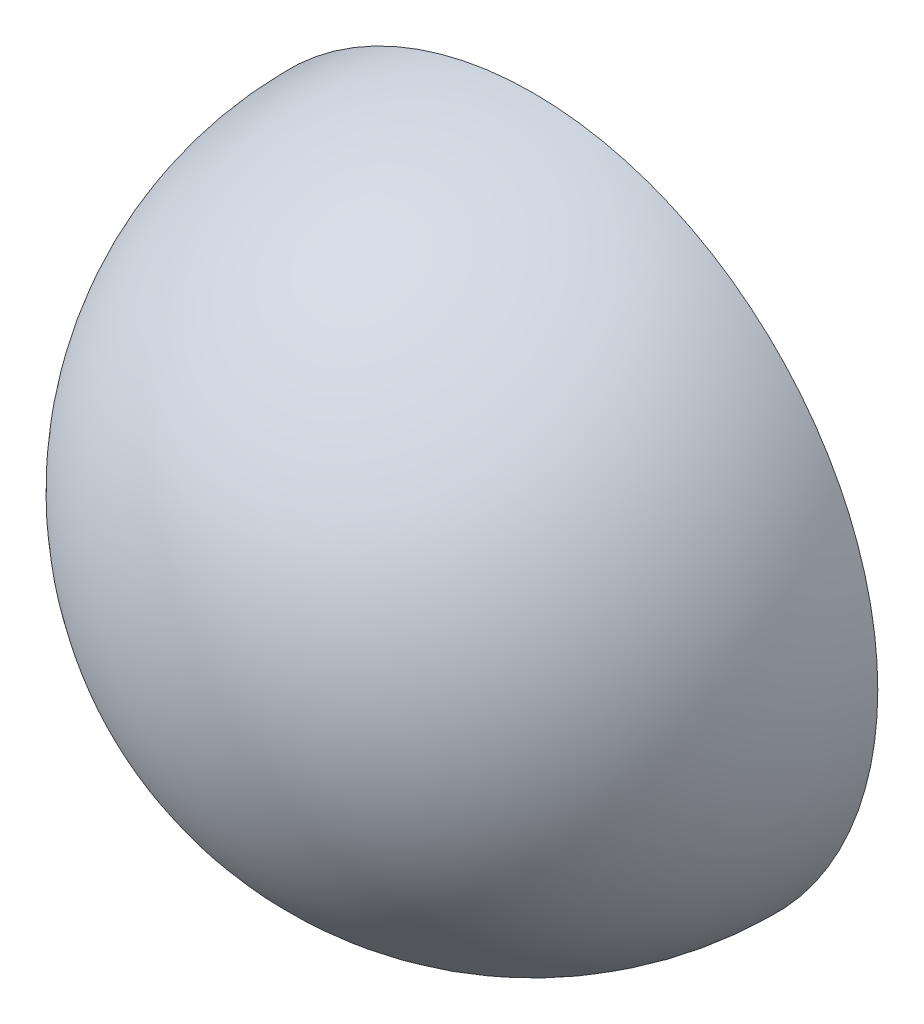
from build123d import *


with BuildPart() as part:
    # Sketch1 → Revolve1 (revolve)
    with BuildSketch(Plane(origin=(0, 0, 0), x_dir=(1, 0, 0), z_dir=(0, 1, 0))):
        with BuildLine():
            Line((-1.25, 0), (0, 0))
            Line((0, 0), (0, -1.25))
            ThreePointArc((0, -1.25), (-0.883883476, -0.883883476), (-1.25, 0))
        make_face()
    revolve(axis=Axis((0, 0, 1.25), (0, 0, -1)))


solid = part.part
